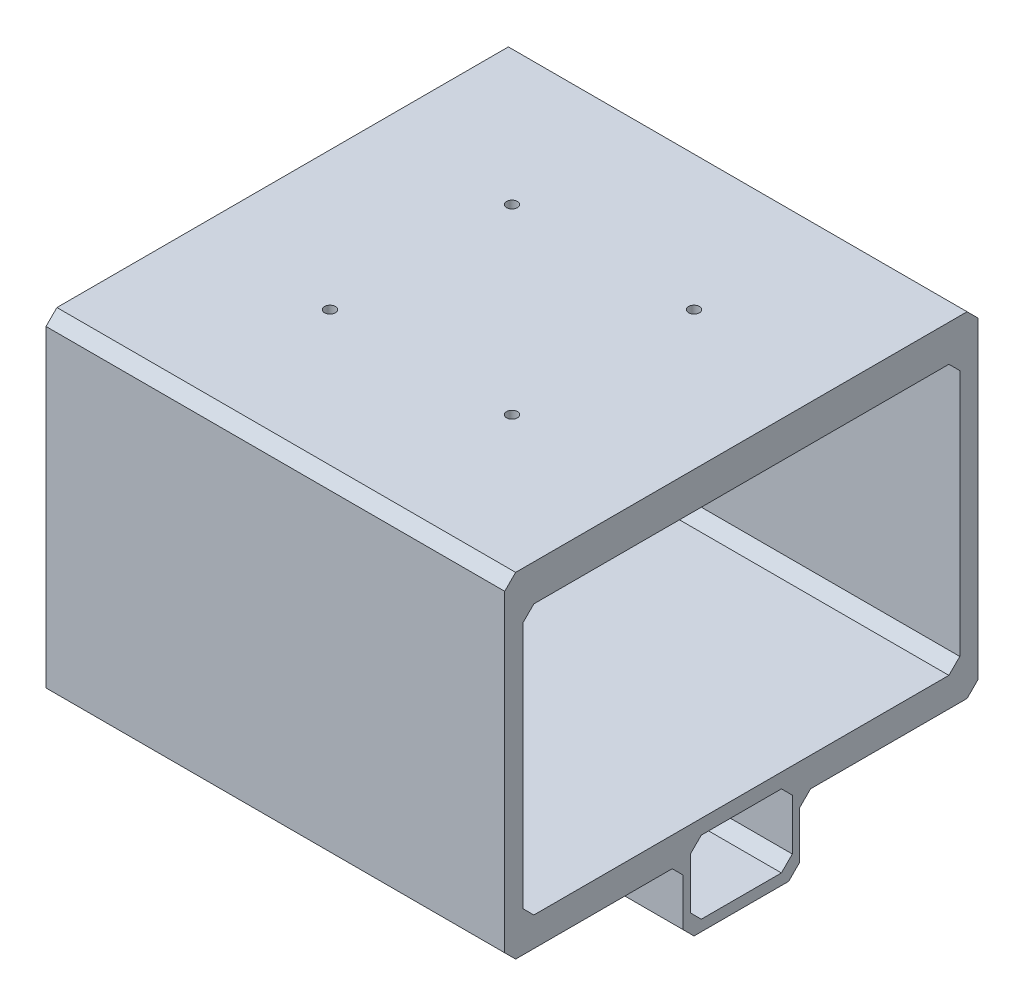
from build123d import *

# Parameters (mm, degrees)
SKETCH1_W           = 126
SKETCH1_H           = 130
SKETCH1_R           = 1.5
BOSS_EXTRUDE1_DEPTH = 10
SKETCH3_W           = 126
SKETCH3_H           = 5
BOSS_EXTRUDE2_DEPTH = 82
BOSS_EXTRUDE4_DEPTH = 126
SKETCH5_R           = 1.5
CUT_EXTRUDE1_DEPTH  = 3
SKETCH6_R           = 1.5
CUT_EXTRUDE2_DEPTH  = 2
CHAMFER1_SIZE       = 3


with BuildPart() as part:
    # Sketch1 → Boss-Extrude1 (new body)
    with BuildSketch(Plane(origin=(0, 0, 0), x_dir=(1, 0, 0), z_dir=(0, 1, 0))):
        with Locations((63, -65)):
            Rectangle(SKETCH1_W, SKETCH1_H)
        with Locations(Location((38, -40, 0), (0, 0, 270))):
            Circle(SKETCH1_R, mode=Mode.SUBTRACT)
        with Locations(Location((88, -40, 0), (0, 0, 270))):
            Circle(SKETCH1_R, mode=Mode.SUBTRACT)
        with Locations(Location((88, -90, 0), (0, 0, 270))):
            Circle(SKETCH1_R, mode=Mode.SUBTRACT)
        with Locations(Location((38, -90, 0), (0, 0, 270))):
            Circle(SKETCH1_R, mode=Mode.SUBTRACT)
    extrude(amount=BOSS_EXTRUDE1_DEPTH)

    # Sketch3 → Boss-Extrude2 (add)
    with BuildSketch(Plane.XZ):
        with Locations((63, 127.5)):
            Rectangle(SKETCH3_W, SKETCH3_H)
        with Locations((63, 2.5)):
            Rectangle(SKETCH3_W, SKETCH3_H)
    extrude(amount=BOSS_EXTRUDE2_DEPTH)

    # Sketch4 → Boss-Extrude4 (add)
    with BuildSketch(Plane(origin=(126, 0, 0), x_dir=(0, 0, -1), z_dir=(1, 0, 0))):
        Polygon((-125, -74), (-125, -82), (-81, -82), (-81, -76), (-65, -76), (-65, -74), align=None)
        Polygon((-81, -76), (-81, -82), (-79, -82), (-79, -78), (-65, -78), (-65, -76), align=None)
        Polygon((-79, -82), (-81, -82), (-81, -101), (-49, -101), (-49, -82), (-51, -82), (-51, -98), (-79, -98), align=None)
        Polygon((-49, -76), (-65, -76), (-65, -78), (-51, -78), (-51, -82), (-49, -82), align=None)
        Polygon((-5, -74), (-65, -74), (-65, -76), (-49, -76), (-49, -82), (-5, -82), align=None)
    extrude(amount=-BOSS_EXTRUDE4_DEPTH)

    # Sketch5 → Cut-Extrude1 (cut)
    with BuildSketch(Plane.XZ.offset(101)):
        with Locations(Location((25, 65, 0), (0, 0, 270))):
            Circle(SKETCH5_R)
        with Locations(Location((63, 65, 0), (0, 0, 270))):
            Circle(SKETCH5_R)
        with Locations(Location((101, 65, 0), (0, 0, 270))):
            Circle(SKETCH5_R)
    extrude(amount=-CUT_EXTRUDE1_DEPTH, mode=Mode.SUBTRACT)

    # Sketch6 → Cut-Extrude2 (cut)
    with BuildSketch(Plane.XY.offset(81)):
        with Locations((106, -91)):
            Circle(SKETCH6_R)
        with Locations((63, -91)):
            Circle(SKETCH6_R)
        with Locations((20, -91)):
            Circle(SKETCH6_R)
    extrude(amount=-CUT_EXTRUDE2_DEPTH, mode=Mode.SUBTRACT)

    # Chamfer1
    chamfer1_edges = [part.edges().sort_by_distance(p)[0] for p in [
        (63, 10, 0),
        (63, 0, 125),
        (63, -82, 130),
        (63, 0, 5),
        (63, -82, 0),
        (63, -78, 51),
        (63, -78, 79),
        (63, -98, 79),
        (63, -82, 49),
        (63, -101, 49),
        (63, -101, 81),
        (63, -82, 81),
        (63, -74, 125),
        (63, -74, 5),
        (63, -98, 51),
        (63, 10, 130),
    ]]
    chamfer(chamfer1_edges, length=CHAMFER1_SIZE)


solid = part.part
